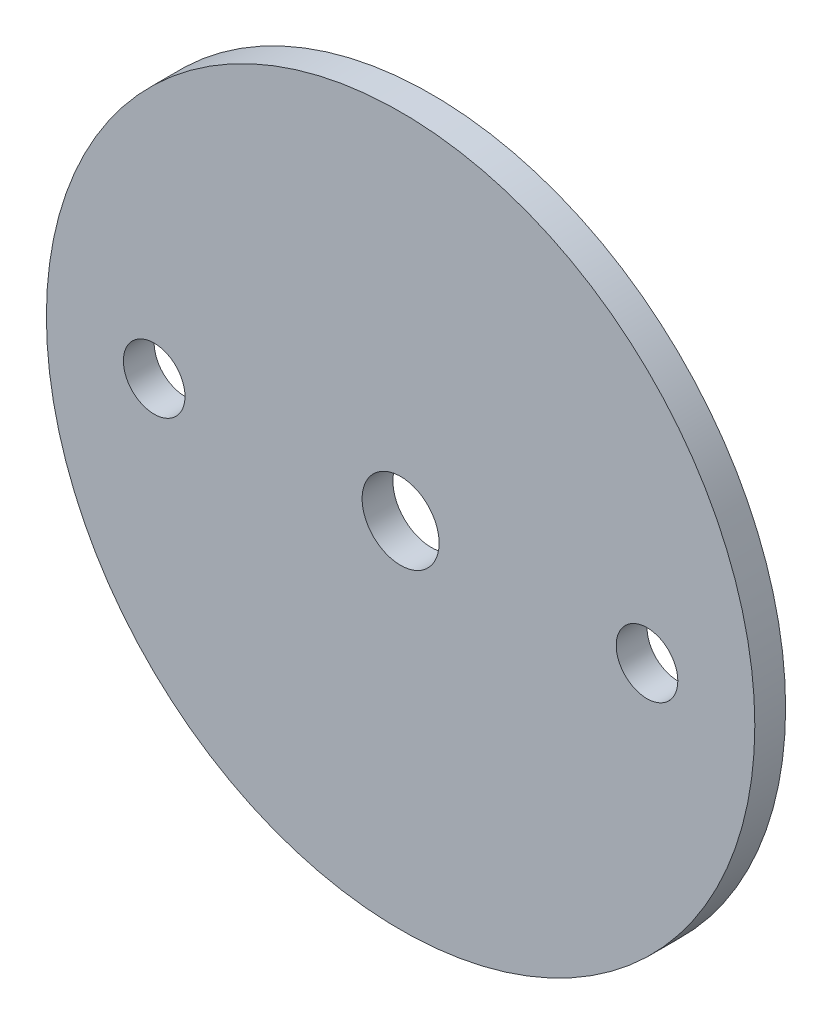
from build123d import *

# Parameters (mm, degrees)
SKETCH1_R                          = 36.5125
BOSS_EXTRUDE1_DEPTH                = 1.5875
F_1_4_0_25_DIAMETER_HOLE1_D        = 6.35
F_5_16_0_3125_DIAMETER_HOLE1_D     = 7.9375
F_5_16_0_3125_DIAMETER_HOLE1_DEPTH = 3.302


with BuildPart() as part:
    # Sketch1 → Boss-Extrude1 (new body, symmetric)
    with BuildSketch(Plane.XY):
        Circle(SKETCH1_R)
    extrude(amount=BOSS_EXTRUDE1_DEPTH, both=True)

    # 1/4 (0.25) Diameter Hole1 (through all)
    with Locations(Plane.XY.offset(1.5875)):
        with Locations((-25.4, 0), (25.4, 0)):
            Hole(F_1_4_0_25_DIAMETER_HOLE1_D / 2)

    # 5/16 (0.3125) Diameter Hole1
    with Locations(Plane.XY.offset(1.5875)):
        with Locations((0, 0)):
            Hole(F_5_16_0_3125_DIAMETER_HOLE1_D / 2, depth=F_5_16_0_3125_DIAMETER_HOLE1_DEPTH)


solid = part.part
